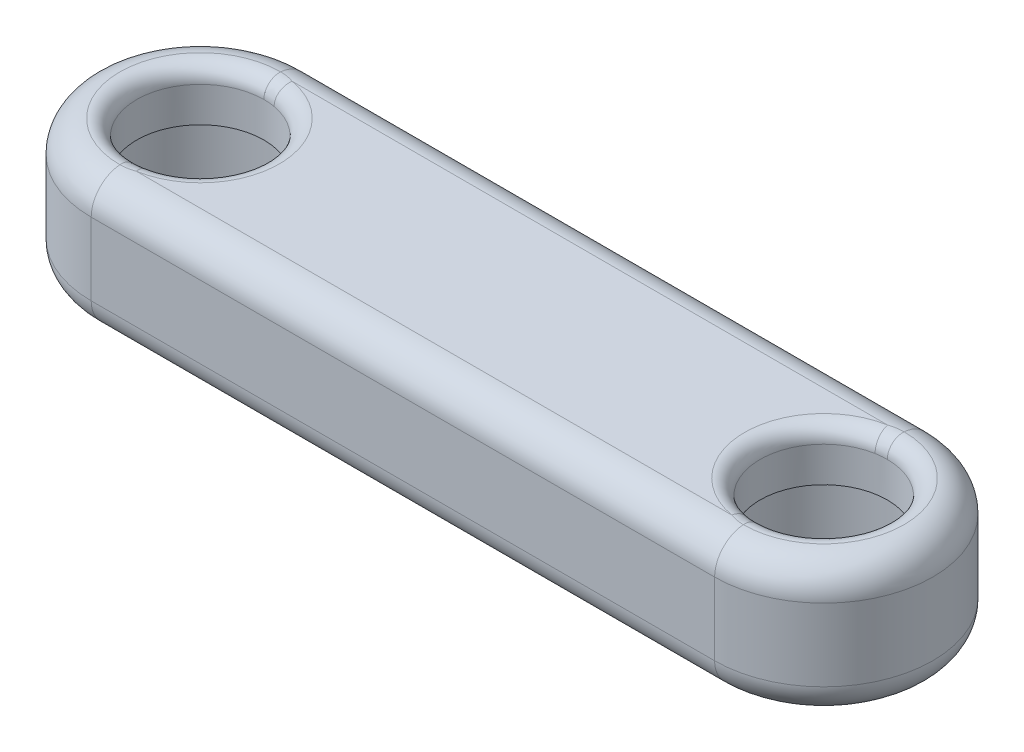
from build123d import *

# Parameters (mm, degrees)
SKETCH1_R           = 4.08
BOSS_EXTRUDE1_DEPTH = 8.65
CUT_EXTRUDE1_START  = -1
SKETCH2_R           = 5.08
CUT_EXTRUDE1_DEPTH  = 4.4
FILLET1_R           = 2
FILLET2_R           = 1


with BuildPart() as part:
    # Sketch1 → Boss-Extrude1 (new body)
    with BuildSketch(Plane(origin=(0, 0, 0), x_dir=(1, 0, 0), z_dir=(0, 1, 0))):
        with BuildLine():
            Line((-20, 7), (20, 7))
            ThreePointArc((20, 7), (27, 0), (20, -7))
            Line((20, -7), (-20, -7))
            ThreePointArc((-20, -7), (-27, 0), (-20, 7))
        make_face()
        with Locations((-20, 0)):
            Circle(SKETCH1_R, mode=Mode.SUBTRACT)
        with Locations((20, 0)):
            Circle(SKETCH1_R, mode=Mode.SUBTRACT)
    extrude(amount=BOSS_EXTRUDE1_DEPTH)

    # Sketch2 → Cut-Extrude1 (cut)
    with BuildSketch(Plane.XZ.offset(CUT_EXTRUDE1_START)):
        with Locations((-20, 0)):
            Circle(SKETCH2_R)
        with Locations((20, 0)):
            Circle(SKETCH2_R)
    extrude(amount=-CUT_EXTRUDE1_DEPTH, mode=Mode.SUBTRACT)

    # Fillet1
    fillet1_edges = [part.edges().sort_by_distance(p)[0] for p in [
        (27, 8.65, 0),
        (0, 8.65, -7),
        (-27, 8.65, 0),
        (0, 0, -7),
        (27, 0, 0),
        (0, 0, 7),
        (-27, 0, 0),
        (0, 8.65, 7),
    ]]
    fillet(fillet1_edges, radius=FILLET1_R)

    # Fillet2
    fillet2_edges = [part.edges().sort_by_distance(p)[0] for p in [
        (-24.08, 8.65, 0),
        (15.92, 8.65, 0),
    ]]
    fillet(fillet2_edges, radius=FILLET2_R)


solid = part.part
